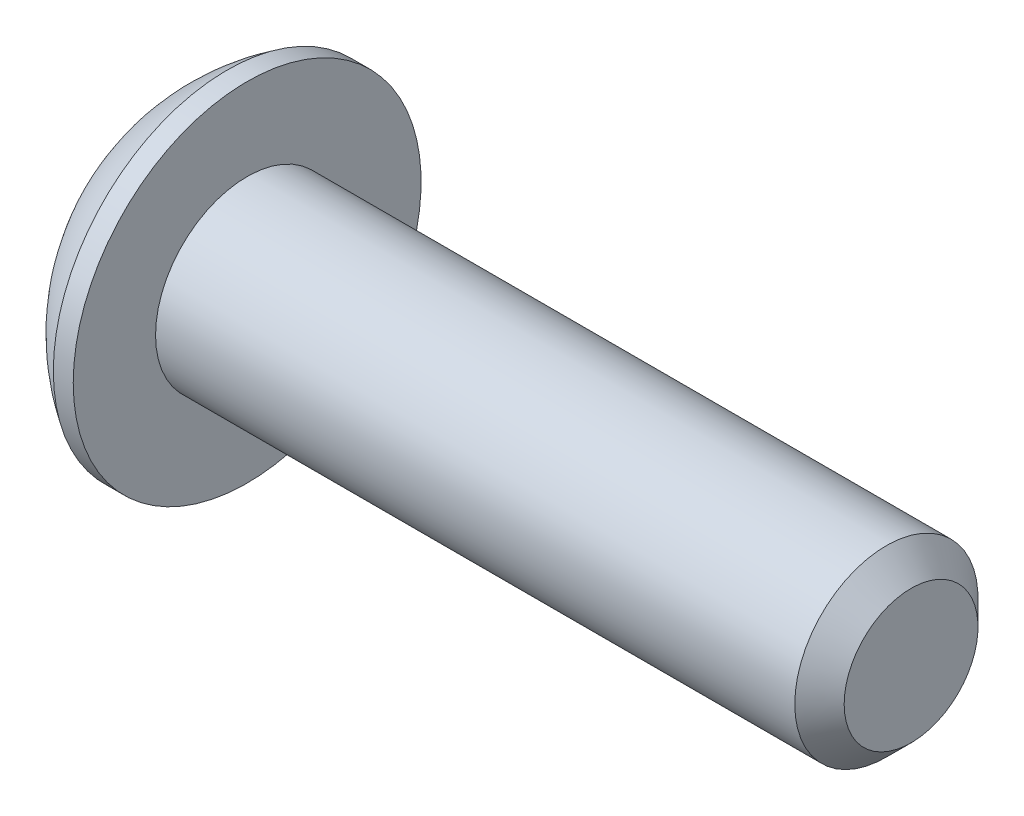
from build123d import *

# Parameters (mm, degrees)
HEX_2_DEPTH = 1.1176


with BuildPart() as part:
    # BodySke → BaseBody (revolve)
    with BuildSketch(Plane.XY):
        with BuildLine():
            Line((14.5542, 0), (14.5542, 1.28016))
            Line((14.5542, 1.28016), (14.08176, 1.7526))
            Line((14.08176, 1.7526), (1.8542, 1.7526))
            Line((1.8542, 1.7526), (1.8542, 3.3274))
            Line((1.8542, 3.3274), (1.4732, 3.3274))
            ThreePointArc((1.4732, 3.3274), (0.616396771, 2.601989501), (0, 1.6637))
            Line((0, 1.6637), (0, 0))
            Line((0, 0), (14.5542, 0))
        make_face()
    revolve(axis=Axis((0, 0, 0), (1, 0, 0)))

    # Sketch2 → PreBroach (revolve, cut)
    with BuildSketch(Plane.XY):
        Polygon((0, 0.9906), (1.1176, 0.9906), (1.689523177, 0), (0, 0), align=None)
    revolve(axis=Axis((0, 0, 0), (1, 0, 0)), mode=Mode.SUBTRACT)

    # Sketch3 → Hex 2 (cut)
    with BuildSketch(Plane(origin=(0, 0, 0), x_dir=(0, 0, -1), z_dir=(1, 0, 0))):
        Polygon((-0.9906, -0.571923177), (-0.9906, 0.571923177), (0, 1.143846353), (0.9906, 0.571923177), (0.9906, -0.571923177), (0, -1.143846353), align=None)
    extrude(amount=HEX_2_DEPTH, mode=Mode.SUBTRACT)


solid = part.part
